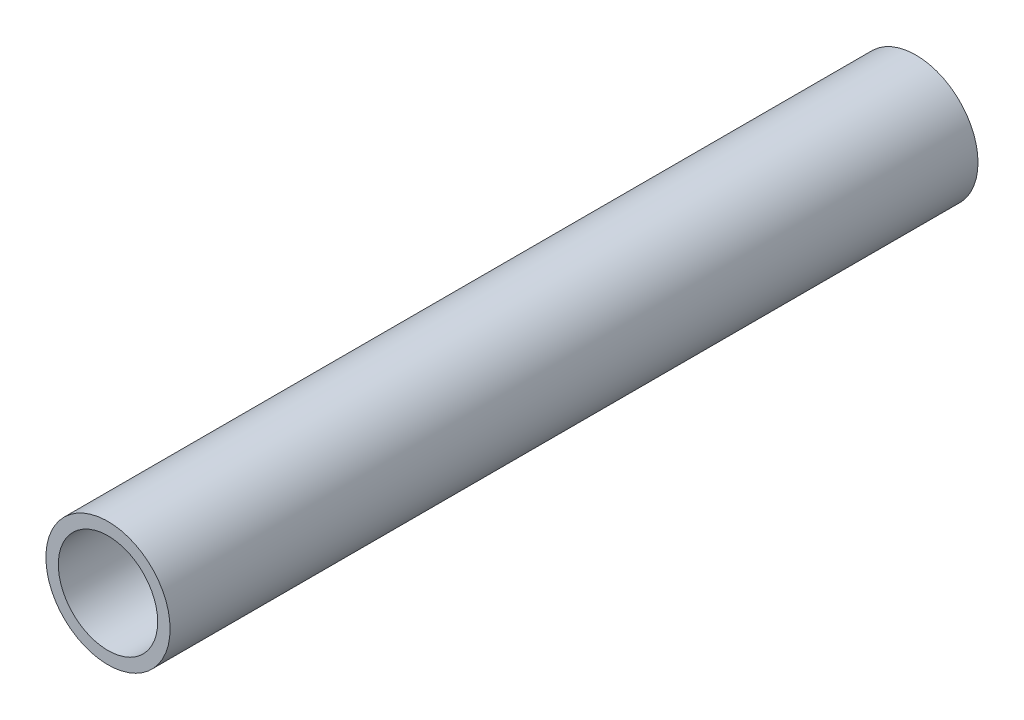
from build123d import *

# Parameters (mm, degrees)
SKETCH1_R           = 1.25
SKETCH1_R_2         = 1
BOSS_EXTRUDE1_DEPTH = 16.26


with BuildPart() as part:
    # Sketch1 → Boss-Extrude1 (new body)
    with BuildSketch(Plane.XY):
        Circle(SKETCH1_R)
        Circle(SKETCH1_R_2, mode=Mode.SUBTRACT)
    extrude(amount=BOSS_EXTRUDE1_DEPTH)


solid = part.part
